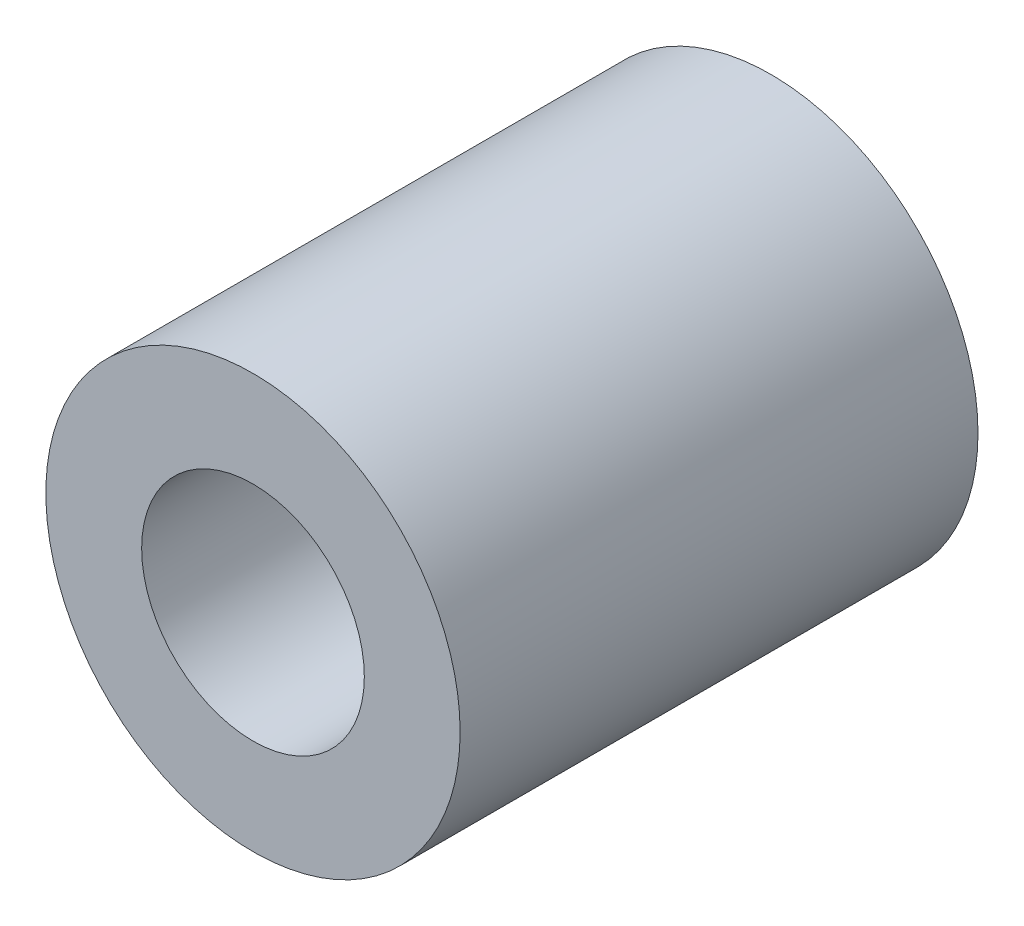
from build123d import *

# Parameters (mm, degrees)
SKETCH_2_R         = 4
EXTRUDE_1_DEPTH    = 10
HOLE_WIZARD_M4_1_D = 4.3


with BuildPart() as part:
    # 草圖2 → 填料-伸長1 (new body)
    with BuildSketch(Plane.XY):
        Circle(SKETCH_2_R)
    extrude(amount=EXTRUDE_1_DEPTH)

    # M4 餘隙孔1 (through all)
    with Locations(Plane.XY.offset(10)):
        with Locations((0, 0)):
            Hole(HOLE_WIZARD_M4_1_D / 2)


solid = part.part
